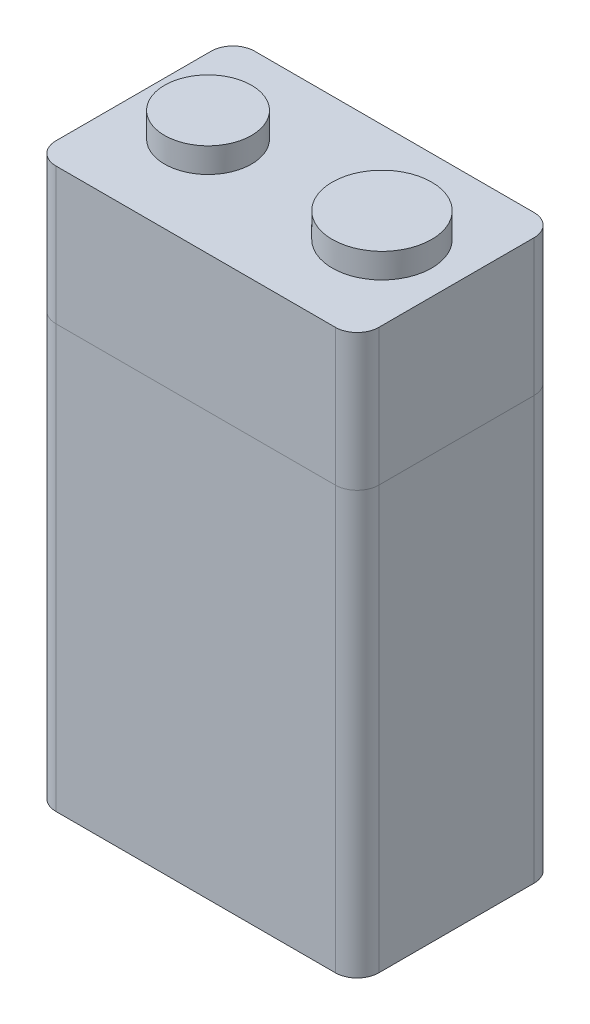
from build123d import *

# Parameters (mm, degrees)
SKETCH1_W           = 26
SKETCH1_H           = 16
BOSS_EXTRUDE1_DEPTH = 45
SKETCH2_R           = 3.5
SKETCH2_R_2         = 4
BOSS_EXTRUDE2_DEPTH = 2
FILLET1_R           = 1.75


with BuildPart() as part:
    # Sketch1 → Boss-Extrude1 (new body)
    with BuildSketch(Plane(origin=(0, 0, 0), x_dir=(1, 0, 0), z_dir=(0, 1, 0))):
        Rectangle(SKETCH1_W, SKETCH1_H)
    extrude(amount=BOSS_EXTRUDE1_DEPTH)

    # Sketch2 → Boss-Extrude2 (add)
    with BuildSketch(Plane(origin=(0, 45, 0), x_dir=(1, 0, 0), z_dir=(0, 1, 0))):
        with Locations((-7, 0)):
            Circle(SKETCH2_R)
        with Locations((7, 0)):
            Circle(SKETCH2_R_2)
    extrude(amount=BOSS_EXTRUDE2_DEPTH)

    # Fillet1
    fillet1_edges = [part.edges().sort_by_distance(p)[0] for p in [
        (13, 22.5, 8),
        (-13, 22.5, 8),
        (-13, 22.5, -8),
        (13, 22.5, -8),
    ]]
    fillet(fillet1_edges, radius=FILLET1_R)


solid = part.part
